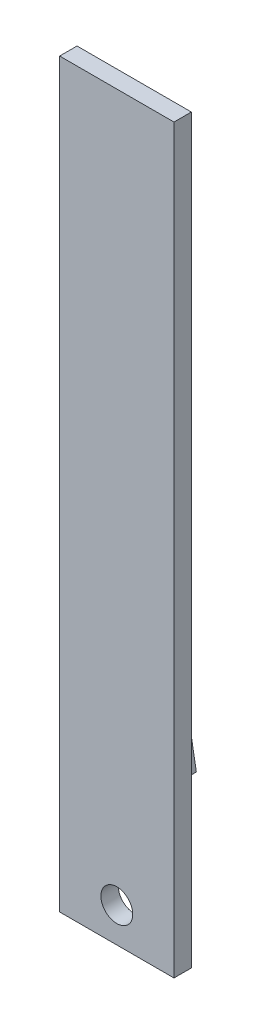
from build123d import *

# Parameters (mm, degrees)
SKETCH1_W               = 20.894747592
SKETCH1_H               = 135.476524453
BOSS_EXTRUDE1_DEPTH     = 3.175
CUT_EXTRUDE2_DEPTH      = 138.1151333
CUT_EXTRUDE2_DEPTH_BACK = 138.1151333
SKETCH2_R               = 2.912030795
SKETCH2_4_R             = 3.450024598
BOSS_EXTRUDE2_DEPTH     = 9.652
BOSS_EXTRUDE3_DEPTH     = 1.27


with BuildPart() as part:
    # Sketch1 → Boss-Extrude1 (new body)
    with BuildSketch(Plane.XY):
        with Locations((-10.447373796, 67.738262226)):
            Rectangle(SKETCH1_W, SKETCH1_H)
    extrude(amount=BOSS_EXTRUDE1_DEPTH)

    # Sketch2 → Cut-Extrude2 (cut, two sides: drawn at the far end of the back side and taken through both)
    with BuildSketch(Plane(origin=(0, 0, 0), x_dir=(-1, 0, 0), z_dir=(0, 0, -1)).offset(-CUT_EXTRUDE2_DEPTH_BACK)):
        with Locations((10.447373796, 6.305347679)):
            Circle(SKETCH2_R)
    extrude(amount=CUT_EXTRUDE2_DEPTH + CUT_EXTRUDE2_DEPTH_BACK, mode=Mode.SUBTRACT)

    # Sketch2_4 → Boss-Extrude2 (add)
    with BuildSketch(Plane(origin=(0, 0, 0), x_dir=(-1, 0, 0), z_dir=(0, 0, -1))):
        with Locations((15.198897526, 22.445779357)):
            Circle(SKETCH2_4_R)
    extrude(amount=BOSS_EXTRUDE2_DEPTH)

    # Sketch3 → Boss-Extrude3 (add)
    with BuildSketch(Plane(origin=(0, 0, -9.652), x_dir=(-1, 0, 0), z_dir=(0, 0, -1))):
        Polygon((10.964889393, 25.99164554), (10.011083267, 20.551953845), (14.2450914, 17.006087662), (19.432905659, 18.899913174), (20.386711785, 24.339604868), (16.152703653, 27.885471051), align=None)
    extrude(amount=BOSS_EXTRUDE3_DEPTH)


solid = part.part
